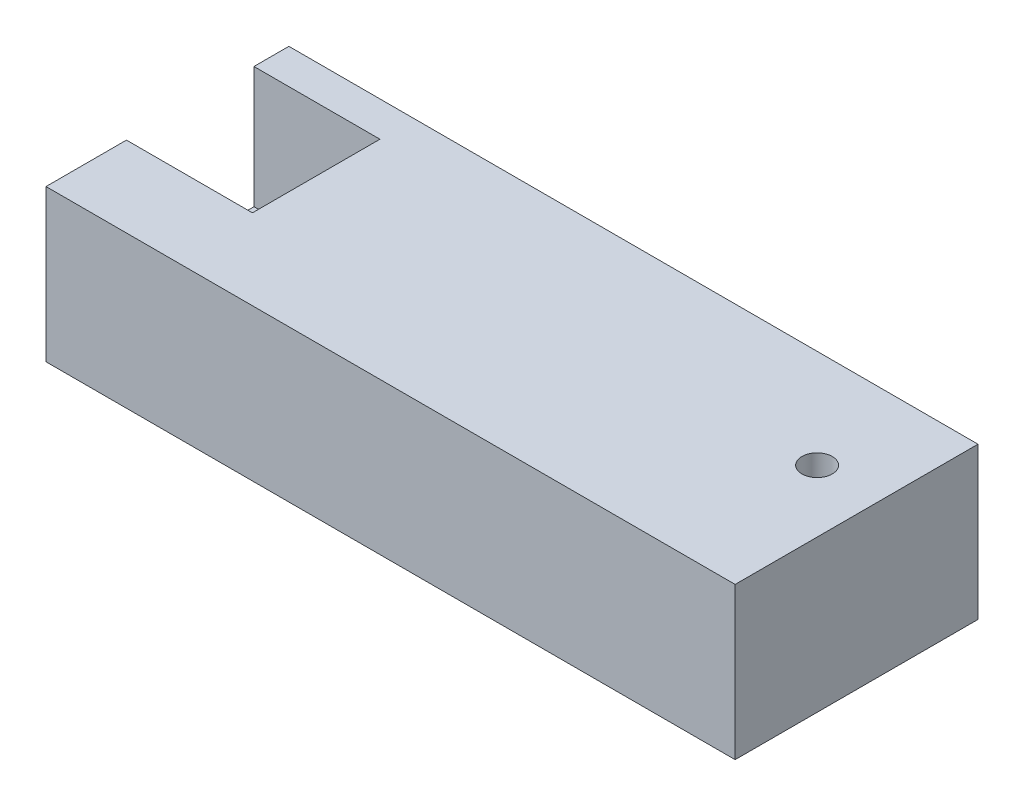
from build123d import *

# Parameters (mm, degrees)
SKETCH1_W           = 227
SKETCH1_H           = 80
SKETCH1_R           = 5
BOSS_EXTRUDE1_DEPTH = 50
SKETCH2_W           = 42
SKETCH2_H           = 42
CUT_EXTRUDE1_DEPTH  = 40


with BuildPart() as part:
    # Sketch1 → Boss-Extrude1 (new body)
    with BuildSketch(Plane(origin=(0, 0, 0), x_dir=(1, 0, 0), z_dir=(0, 1, 0))):
        Rectangle(SKETCH1_W, SKETCH1_H)
        with Locations((-93, 7.5)):
            Circle(SKETCH1_R, mode=Mode.SUBTRACT)
        with Locations((93, 7.5)):
            Circle(SKETCH1_R, mode=Mode.SUBTRACT)
    extrude(amount=BOSS_EXTRUDE1_DEPTH)

    # Sketch2 → Cut-Extrude1 (cut)
    with BuildSketch(Plane(origin=(0, 50, 0), x_dir=(1, 0, 0), z_dir=(0, 1, 0))):
        with Locations((-93, 7.5)):
            Rectangle(SKETCH2_W, SKETCH2_H)
    extrude(amount=-CUT_EXTRUDE1_DEPTH, mode=Mode.SUBTRACT)


solid = part.part
